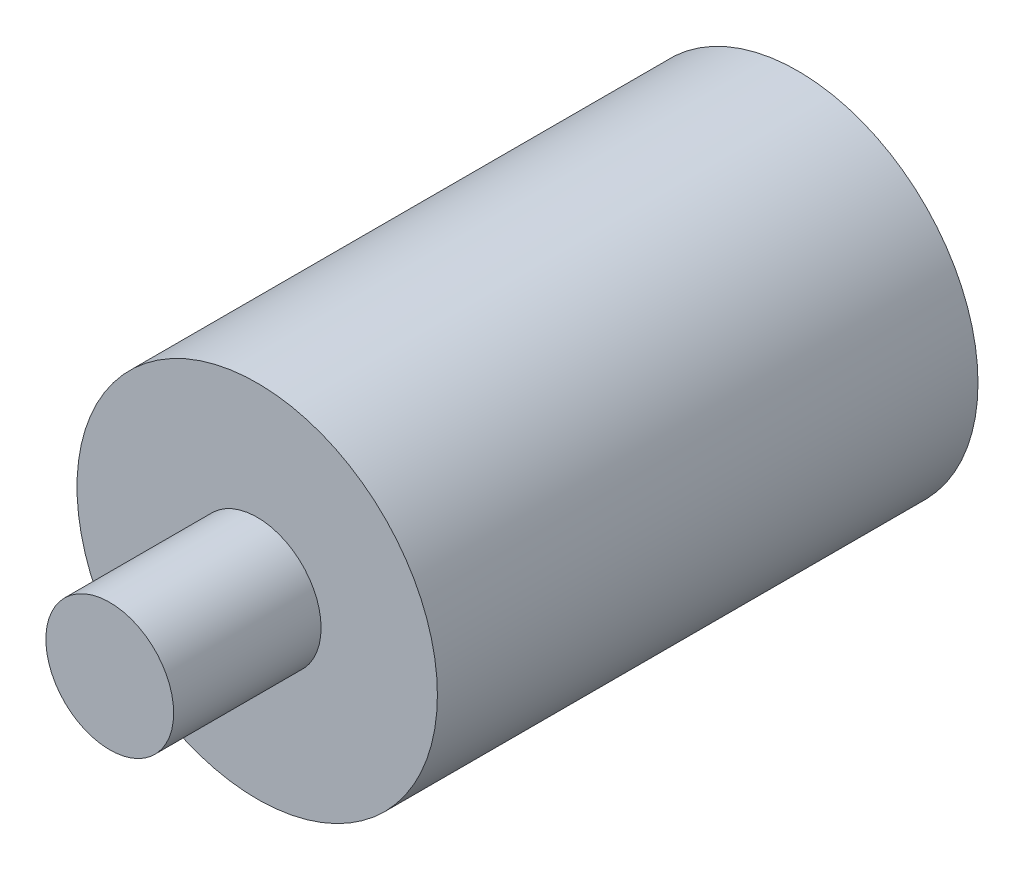
from build123d import *

# Parameters (mm, degrees)
ESQUISSE1_R        = 11
BOSS_EXTRU_1_DEPTH = 33
ESQUISSE2_R        = 3.9
BOSS_EXTRU_2_DEPTH = 9


with BuildPart() as part:
    # Esquisse1 → Boss.-Extru.1 (new body)
    with BuildSketch(Plane.XY):
        Circle(ESQUISSE1_R)
    extrude(amount=BOSS_EXTRU_1_DEPTH)

    # Esquisse2 → Boss.-Extru.2 (add)
    with BuildSketch(Plane.XY.offset(33)):
        Circle(ESQUISSE2_R)
    extrude(amount=BOSS_EXTRU_2_DEPTH)


solid = part.part
